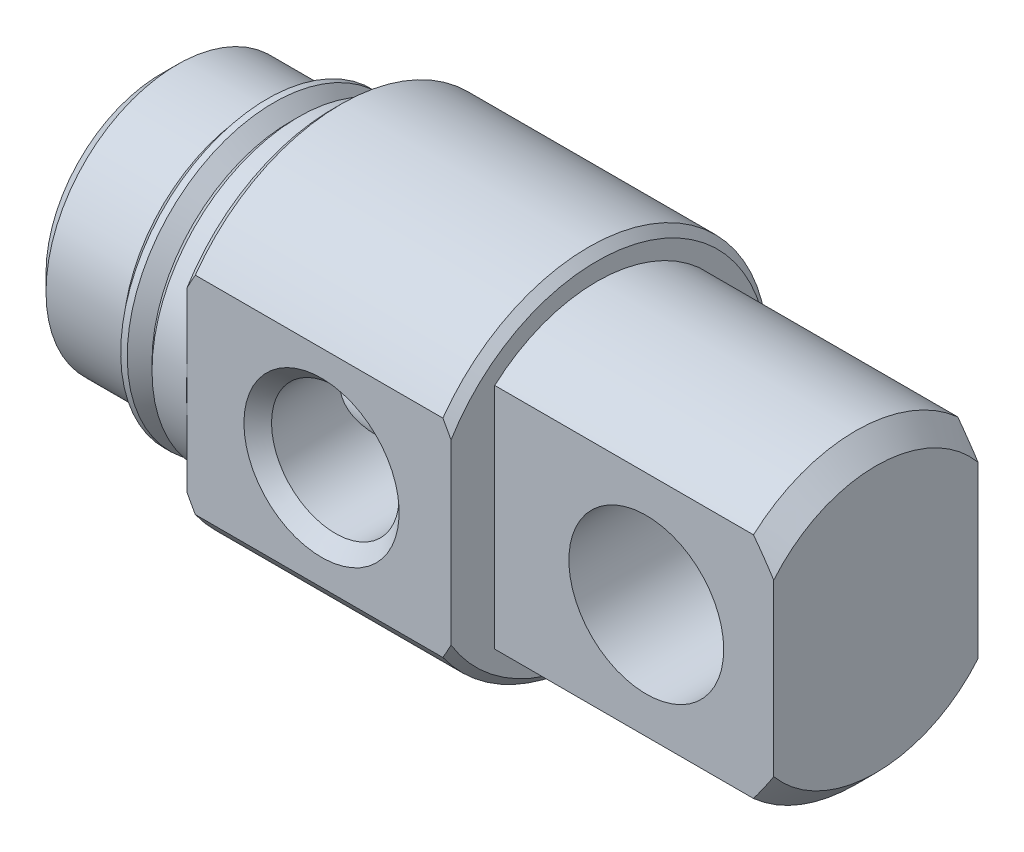
from build123d import *

# Parameters (mm, degrees)
SKETCH3_W               = 22.2504
SKETCH3_H               = 44.5008
SKETCH3_W_2             = 6.35
SKETCH3_H_2             = 22.2504
CUT_EXTRUDE1_DEPTH      = 8.6741
SKETCH4_W               = 5.5626
SKETCH4_H               = 11.1252
CUT_EXTRUDE2_DEPTH      = 8.2042
SKETCH8_R               = 2.40665
CUT_EXTRUDE3_DEPTH      = 4.7625
CUT_EXTRUDE3_DEPTH_BACK = 4.7625


with BuildPart() as part:
    # Sketch1 → Revolve1 (revolve)
    with BuildSketch(Plane.XY):
        Polygon((0, 0), (0, 3.57505), (0.508, 4.08305), (2.9083, 4.08305), (3.4671, 3.52425), (4.0259, 3.52425), (4.0259, 4.3053), (4.2799, 4.5593), (5.3467, 4.5593), (5.3467, 5.3086), (5.6007, 5.5626), (13.2969, 5.5626), (13.5509, 5.3086), (13.5509, 0), align=None)
    revolve(axis=Axis((13.5509, 0, 0), (-1, 0, 0)))

    # Sketch2 → Revolve2 (revolve)
    with BuildSketch(Plane.XY):
        Polygon((13.5509, 0), (13.5509, 4.7625), (21.59508, 4.7625), (22.225, 4.13258), (22.225, 0), align=None)
    revolve(axis=Axis((22.225, 0, 0), (-1, 0, 0)))

    # Sketch3 → Cut-Extrude1 (cut)
    with BuildSketch(Plane(origin=(22.225, 0, 0), x_dir=(0, 0, -1), z_dir=(1, 0, 0))):
        Rectangle(SKETCH3_W, SKETCH3_H)
        Rectangle(SKETCH3_W_2, SKETCH3_H_2, mode=Mode.SUBTRACT)
    extrude(amount=-CUT_EXTRUDE1_DEPTH, mode=Mode.SUBTRACT)

    # Sketch4 → Cut-Extrude2 (cut)
    with BuildSketch(Plane(origin=(13.5509, 0, 0), x_dir=(0, 0, -1), z_dir=(1, 0, 0))):
        with Locations((-7.3152, 0)):
            Rectangle(SKETCH4_W, SKETCH4_H)
    extrude(amount=-CUT_EXTRUDE2_DEPTH, mode=Mode.SUBTRACT)

    # Sketch5 → Cut-Revolve1 (revolve, cut)
    with BuildSketch(Plane.XY):
        Polygon((0, 0), (0, 1.98374), (13.5509, 1.98374), (14.696212823, 0), align=None)
    revolve(axis=Axis((14.696212823, 0, 0), (-1, 0, 0)), mode=Mode.SUBTRACT)

    # Sketch6 → Cut-Revolve2 (revolve, cut)
    with BuildSketch(Plane(origin=(0, 0, 0), x_dir=(1, 0, 0), z_dir=(0, 1, 0))):
        Polygon((9.525, 0), (11.50874, 0), (11.50874, -4.10464), (11.938, -4.5339), (9.525, -4.5339), align=None)
    revolve(axis=Axis((9.525, 0, 4.5339), (0, 0, -1)), mode=Mode.SUBTRACT)

    # Sketch7 → Revolve3 (revolve)
    with BuildSketch(Plane.XY):
        with BuildLine():
            Line((3.306480735, 4.5593), (3.306480735, 4.475131804))
            Line((3.306480735, 4.475131804), (3.912128708, 3.869483831))
            ThreePointArc((3.912128708, 3.869483831), (3.949326147, 3.779681269), (3.912128708, 3.689878708))
            Line((3.912128708, 3.689878708), (3.7465, 3.52425))
            Line((3.7465, 3.52425), (3.4671, 3.52425))
            Line((3.4671, 3.52425), (3.4671, 3.27025))
            Line((3.4671, 3.27025), (4.0259, 3.27025))
            Line((4.0259, 3.27025), (4.0259, 4.043080735))
            Line((4.0259, 4.043080735), (3.509680735, 4.5593))
            Line((3.509680735, 4.5593), (3.306480735, 4.5593))
        make_face()
    revolve(axis=Axis((4.0259, 0, 0), (-1, 0, 0)))

    # Sketch8 → Cut-Extrude3 (cut, two sides)
    with BuildSketch(Plane.XY) as cut_extrude3_sk:
        with Locations((18.2626, 0)):
            Circle(SKETCH8_R)
    extrude(amount=CUT_EXTRUDE3_DEPTH, mode=Mode.SUBTRACT)
    extrude(cut_extrude3_sk.sketch, amount=-CUT_EXTRUDE3_DEPTH_BACK, mode=Mode.SUBTRACT)


solid = part.part
